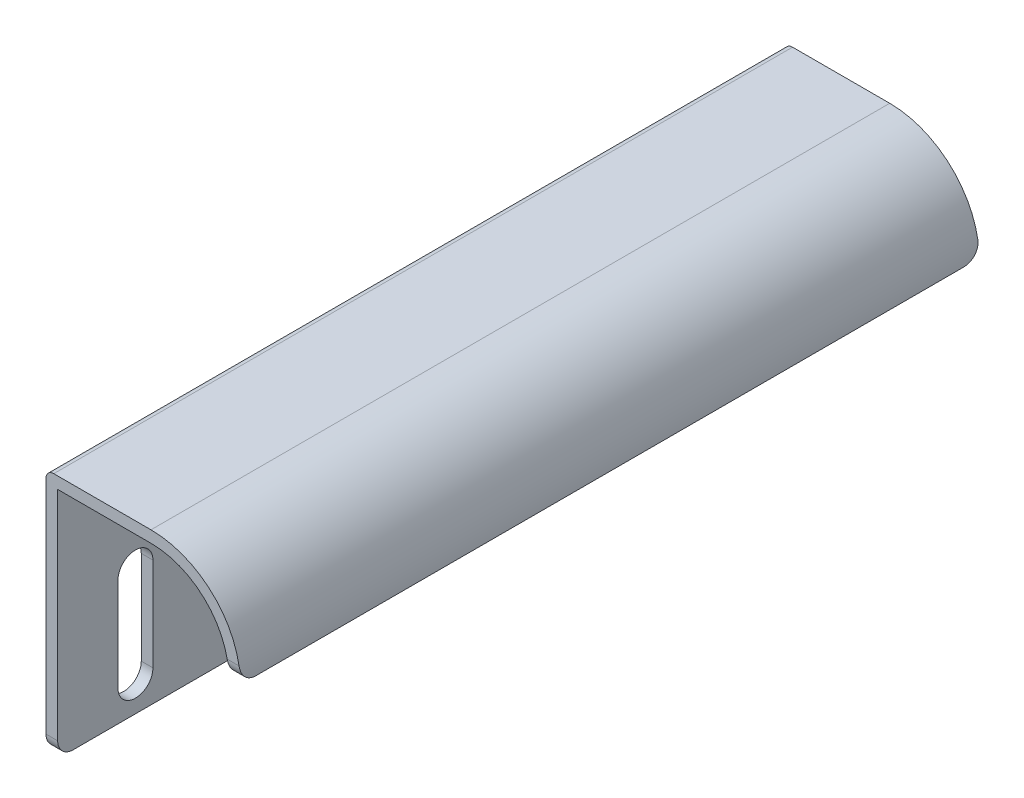
from build123d import *

# Parameters (mm, degrees)
BOSS_EXTRUDE1_DEPTH = 95
FILLET1_R           = 1
FILLET2_R           = 2
CUT_EXTRUDE1_DEPTH  = 2.5


with BuildPart() as part:
    # Sketch1 → Boss-Extrude1 (new body)
    with BuildSketch(Plane.XY):
        with BuildLine():
            Line((-9.763392857, -19.416294643), (-9.763392857, 12.083705357))
            Line((-9.763392857, 12.083705357), (3.736607143, 12.083705357))
            ThreePointArc((3.736607143, 12.083705357), (11.868335127, 8.715433341), (15.236607143, 0.583705357))
            Line((15.236607143, 0.583705357), (13.736607143, 0.583705357))
            ThreePointArc((13.736607143, 0.583705357), (10.807674955, 7.654773169), (3.736607143, 10.583705357))
            Line((3.736607143, 10.583705357), (-8.263392857, 10.583705357))
            Line((-8.263392857, 10.583705357), (-8.263392857, -19.416294643))
            Line((-8.263392857, -19.416294643), (-9.763392857, -19.416294643))
        make_face()
    extrude(amount=BOSS_EXTRUDE1_DEPTH)

    # Fillet1
    fillet1_edges = [part.edges().sort_by_distance(p)[0] for p in [
        (-9.763392857, 12.083705357, 47.5),
    ]]
    fillet(fillet1_edges, radius=FILLET1_R)

    # Fillet2
    fillet2_edges = [part.edges().sort_by_distance(p)[0] for p in [
        (-9.013392857, -19.416294643, 0),
        (14.486607143, 0.583705357, 95),
        (-9.013392857, -19.416294643, 95),
        (14.486607143, 0.583705357, 0),
    ]]
    fillet(fillet2_edges, radius=FILLET2_R)

    # Sketch2 → Cut-Extrude1 (cut, through all)
    with BuildSketch(Plane(origin=(-8.263392857, 0, 0), x_dir=(0, 0, -1), z_dir=(1, 0, 0))):
        with BuildLine():
            Line((-87.25, -3.416294643), (-87.25, -15.416294643))
            ThreePointArc((-87.25, -15.416294643), (-85, -17.666294643), (-82.75, -15.416294643))
            Line((-82.75, -15.416294643), (-82.75, -3.416294643))
            ThreePointArc((-82.75, -3.416294643), (-85, -1.166294643), (-87.25, -3.416294643))
        make_face()
        with BuildLine():
            Line((-12.25, -3.416294643), (-12.25, -15.416294643))
            ThreePointArc((-12.25, -15.416294643), (-10, -17.666294643), (-7.75, -15.416294643))
            Line((-7.75, -15.416294643), (-7.75, -3.416294643))
            ThreePointArc((-7.75, -3.416294643), (-10, -1.166294643), (-12.25, -3.416294643))
        make_face()
    extrude(amount=-CUT_EXTRUDE1_DEPTH, mode=Mode.SUBTRACT)


solid = part.part
